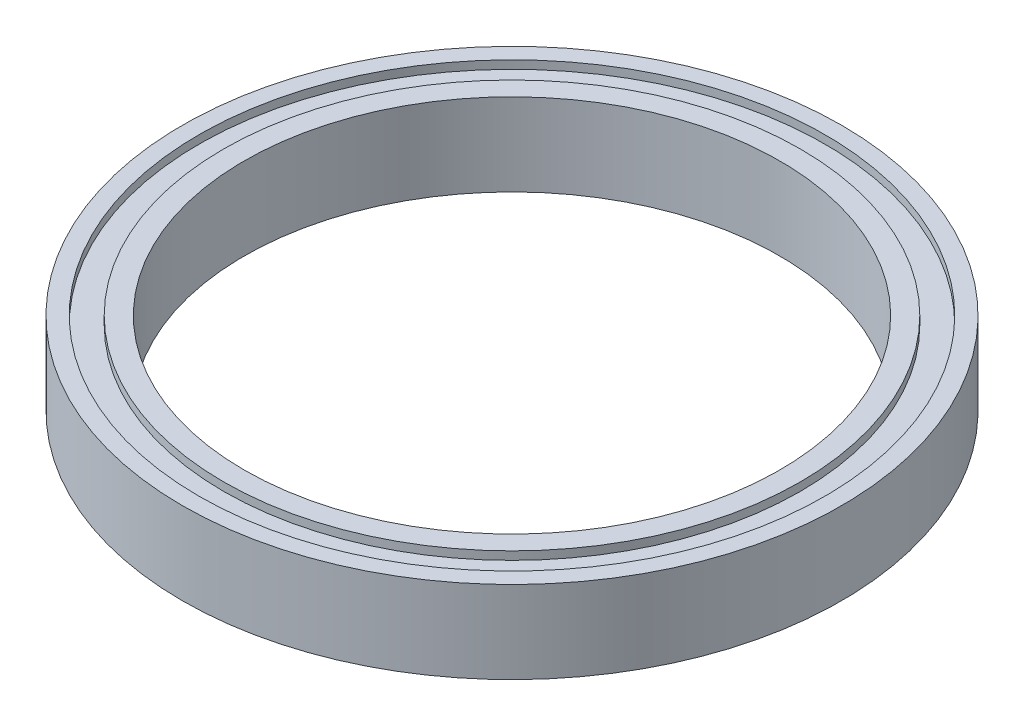
from build123d import *


with BuildPart() as part:
    # 草图2 → 旋转1 (revolve)
    with BuildSketch(Plane.XY):
        Polygon((-38, 16.303928242), (-38, 15.303928242), (-35, 15.303928242), (-35, 16.303928242), (-32.5, 16.303928242), (-32.5, 6.303928242), (-35, 6.303928242), (-35, 7.303928242), (-38, 7.303928242), (-38, 6.303928242), (-40, 6.303928242), (-40, 16.303928242), align=None)
    revolve(axis=Axis((0, 37.480371566, 0), (0, -1, 0)))


solid = part.part
